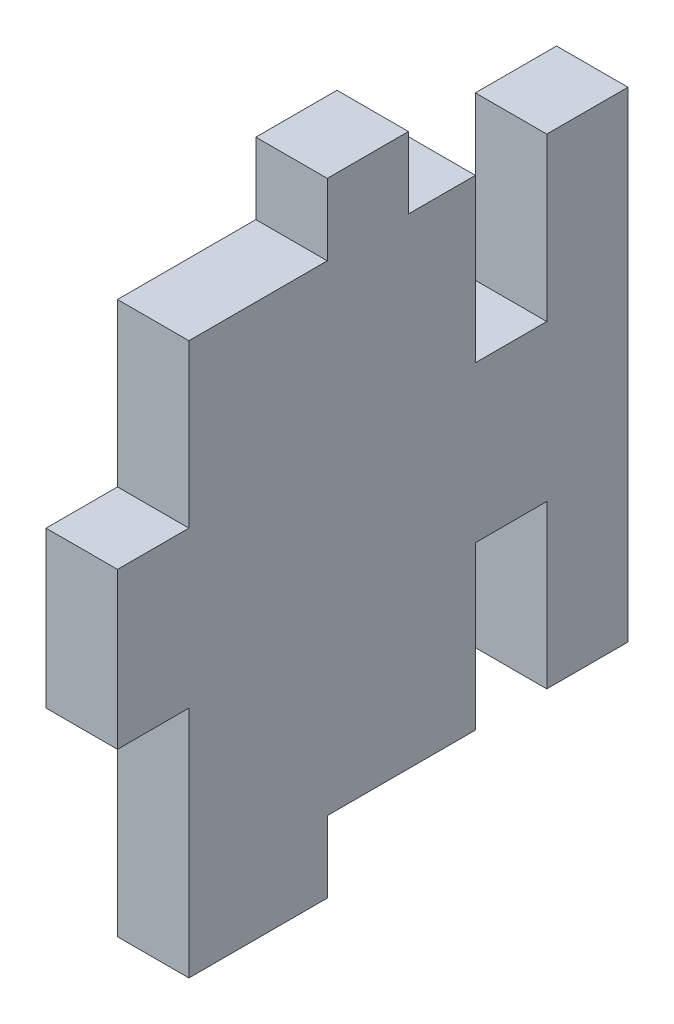
from build123d import *

# Parameters (mm, degrees)
BOSS_EXTRUDE1_DEPTH = 5.588


with BuildPart() as part:
    # Sketch1 → Boss-Extrude1 (new body)
    with BuildSketch(Plane(origin=(0, 0, 0), x_dir=(0, 0, -1), z_dir=(1, 0, 0))):
        Polygon((-3.175, 21.59), (-14, 21.59), (-14, 8.89), (-19.588, 8.89), (-19.588, -3.302), (-14, -3.302), (-14, -21.59), (-3.175, -21.59), (-3.175, -16.002), (8.412, -16.002), (8.412, -3.302), (14, -3.302), (14, -16.002), (20.35, -16.002), (20.35, 21.59), (14, 21.59), (14, 8.89), (8.412, 8.89), (8.412, 21.59), (3.175, 21.59), (3.175, 27.178), (-3.175, 27.178), align=None)
    extrude(amount=BOSS_EXTRUDE1_DEPTH)


solid = part.part
